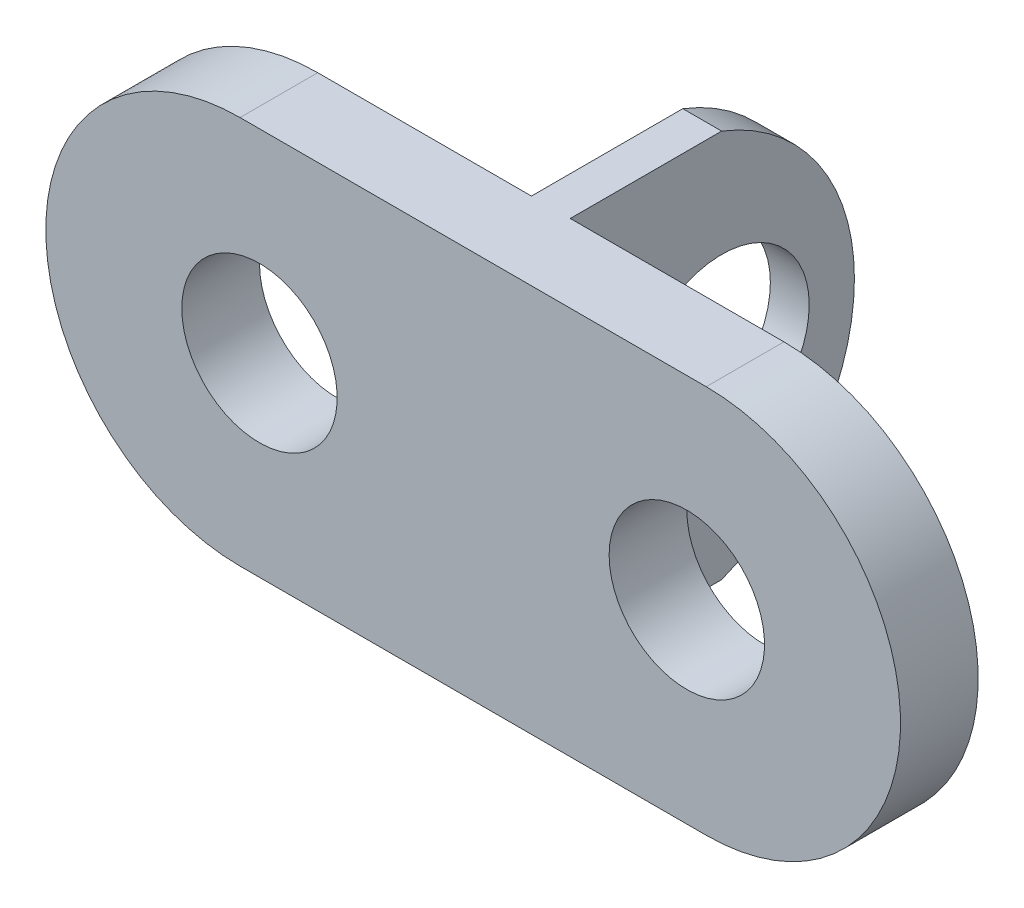
from build123d import *

# Parameters (mm, degrees)
BOSS_EXTRU_1_DEPTH         = 4
ESQUISSE2_W                = 2
ESQUISSE2_H                = 20
BOSS_EXTRU_2_DEPTH         = 15
ESQUISSE3_R                = 4.5
ENL_V_MAT_EXTRU_1_DEPTH    = 24
ESQUISSE4_R                = 4
ENL_V_MAT_EXTRU_2_DEPTH    = 5
R_P_TITION_LIN_AIRE1_COUNT = 2
R_P_TITION_LIN_AIRE1_PITCH = 22


with BuildPart() as part:
    # Esquisse1 → Boss.-Extru.1 (new body)
    with BuildSketch(Plane.XY):
        with BuildLine():
            Line((-2.795180723, 5.068273092), (21.204819277, 5.068273092))
            ThreePointArc((21.204819277, 5.068273092), (31.204819277, -4.931726908), (21.204819277, -14.931726908))
            Line((21.204819277, -14.931726908), (-2.795180723, -14.931726908))
            ThreePointArc((-2.795180723, -14.931726908), (-12.795180723, -4.931726908), (-2.795180723, 5.068273092))
        make_face()
    extrude(amount=BOSS_EXTRU_1_DEPTH)

    # Esquisse2 → Boss.-Extru.2 (add)
    with BuildSketch(Plane.XY):
        with Locations((9.204819277, -4.931726908)):
            Rectangle(ESQUISSE2_W, ESQUISSE2_H)
    extrude(amount=-BOSS_EXTRU_2_DEPTH)

    # Esquisse3 → Enlèv. mat.-Extru.1 (cut, through all)
    with BuildSketch(Plane(origin=(10.204819277, 0, 0), x_dir=(0, 0, -1), z_dir=(1, 0, 0))):
        with BuildLine():
            Line((15, 5.068273092), (7.792478569, 5.068273092))
            ThreePointArc((7.792478569, 5.068273092), (14.628465548, -4.931726908), (7.792478569, -14.931726908))
            Line((7.792478569, -14.931726908), (15, -14.931726908))
            Line((15, -14.931726908), (15, 5.068273092))
        make_face()
        with Locations((7.8, -4.931726908)):
            Circle(ESQUISSE3_R)
    extrude(amount=-ENL_V_MAT_EXTRU_1_DEPTH, mode=Mode.SUBTRACT)

    # Esquisse4 → Enlèv. mat.-Extru.2 (cut, through all)
    with BuildSketch(Plane(origin=(0, 0, 0), x_dir=(-1, 0, 0), z_dir=(0, 0, -1))):
        with Locations((-20.204819277, -4.931726908)):
            Circle(ESQUISSE4_R)
    enl_v_mat_extru_2 = extrude(amount=-ENL_V_MAT_EXTRU_2_DEPTH, mode=Mode.SUBTRACT)

    # Répétition linéaire1: Enlèv. mat.-Extru.2 ×2
    with Locations(*[(-i * R_P_TITION_LIN_AIRE1_PITCH, 0, 0) for i in range(1, R_P_TITION_LIN_AIRE1_COUNT)]):
        add(enl_v_mat_extru_2, mode=Mode.SUBTRACT)


solid = part.part
